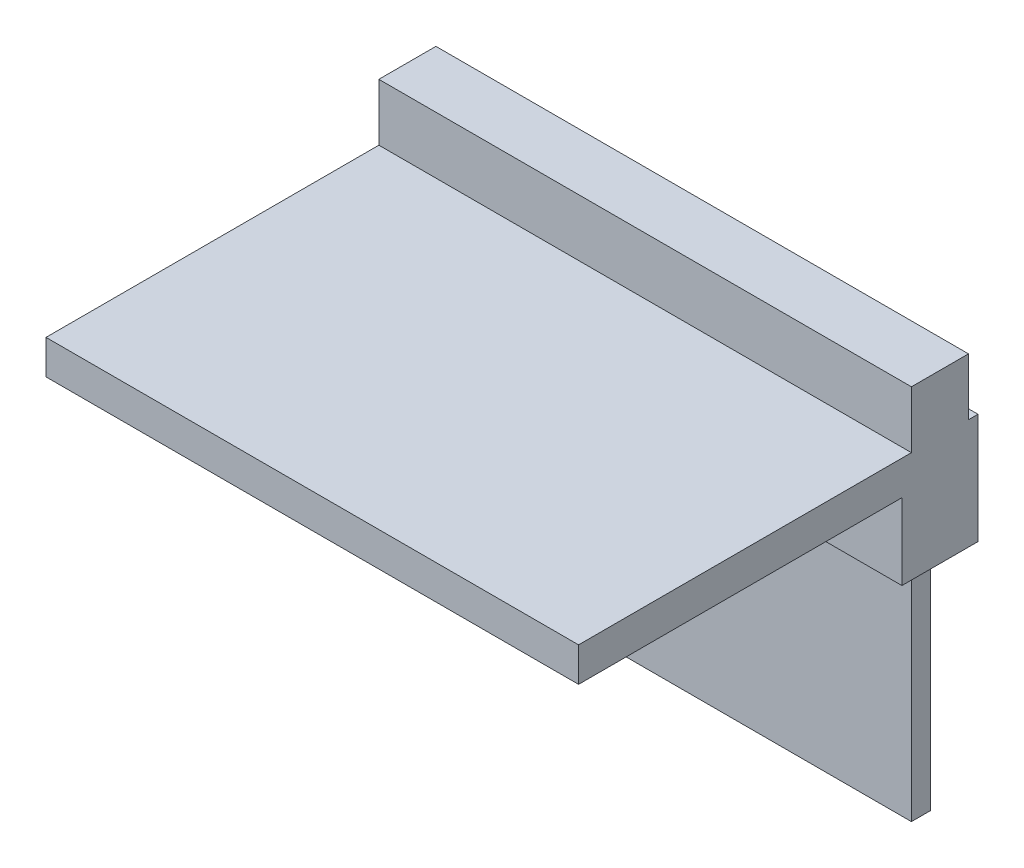
from build123d import *

# Parameters (mm, degrees)
SKETCH_1_W      = 14
SKETCH_1_H      = 10.5
EXTRUDE_1_DEPTH = 0.9
SKETCH_3_W      = 14
SKETCH_3_H      = 2
EXTRUDE_2_DEPTH = 2
SKETCH_4_W      = 13
SKETCH_4_H      = 0.5
EXTRUDE_3_DEPTH = 6
SKETCH_8_W      = 14
SKETCH_8_H      = 1.5
EXTRUDE_4_DEPTH = 1.5


with BuildPart() as part:
    # Эскиз1 → Бобышка-Вытянуть1 (new body)
    with BuildSketch(Plane(origin=(0, 0, 0), x_dir=(1, 0, 0), z_dir=(0, 1, 0))):
        Rectangle(SKETCH_1_W, SKETCH_1_H)
    extrude(amount=EXTRUDE_1_DEPTH)

    # Эскиз3 → Бобышка-Вытянуть2 (add)
    with BuildSketch(Plane.XZ):
        with Locations((0, -4.25)):
            Rectangle(SKETCH_3_W, SKETCH_3_H)
    extrude(amount=EXTRUDE_2_DEPTH)

    # Эскиз4 → Бобышка-Вытянуть3 (add)
    with BuildSketch(Plane.XZ.offset(2)):
        with Locations((0, -4.25)):
            Rectangle(SKETCH_4_W, SKETCH_4_H)
    extrude(amount=EXTRUDE_3_DEPTH)

    # Эскиз8 → Бобышка-Вытянуть4 (add)
    with BuildSketch(Plane(origin=(0, 0.9, 0), x_dir=(1, 0, 0), z_dir=(0, 1, 0))):
        with Locations((0, 4.25)):
            Rectangle(SKETCH_8_W, SKETCH_8_H)
    extrude(amount=EXTRUDE_4_DEPTH)


solid = part.part
